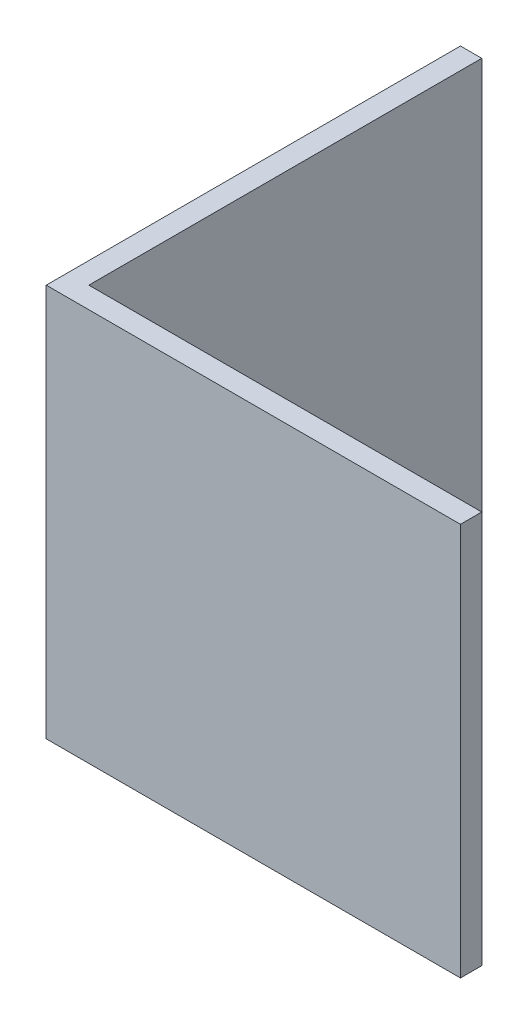
from build123d import *

# Parameters (mm, degrees)
BOSS_EXTRUDE1_DEPTH = 50.8


with BuildPart() as part:
    # Sketch1 → Boss-Extrude1 (new body)
    with BuildSketch(Plane(origin=(0, 0, 0), x_dir=(1, 0, 0), z_dir=(0, 1, 0))):
        Polygon((-26.77668, -26.77668), (26.77668, -26.77668), (26.77668, -24.02332), (-24.02332, -24.02332), (-24.02332, 26.77668), (-26.77668, 26.77668), align=None)
    extrude(amount=BOSS_EXTRUDE1_DEPTH)


solid = part.part
